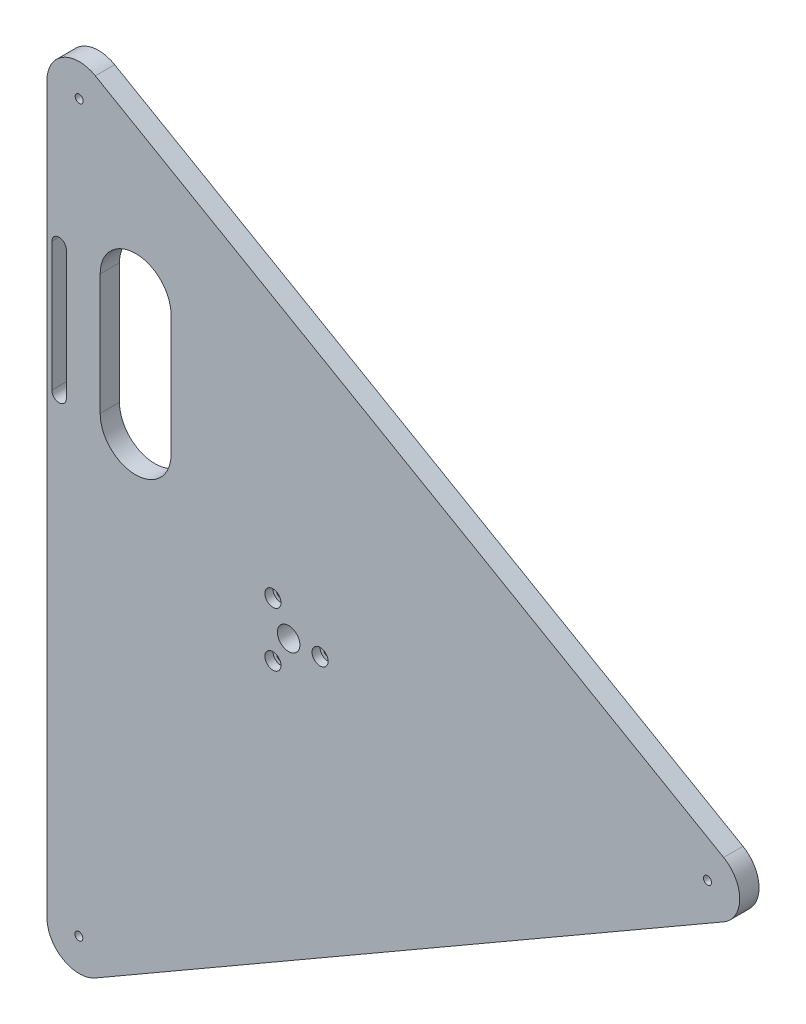
from build123d import *

# Parameters (mm, degrees)
BOSS_EXTRU_1_DEPTH                                 = 12
TROU_TARAUD_M61_D                                  = 5
TROU_TARAUD_M62_D                                  = 5
CHAMBRAGE_POUR_VIS_T_TE_HEXAGONALE_M51_D           = 5.5
CHAMBRAGE_POUR_VIS_T_TE_HEXAGONALE_M51_CBORE_D     = 10
CHAMBRAGE_POUR_VIS_T_TE_HEXAGONALE_M51_CBORE_DEPTH = 5
ESQUISSE11_R                                       = 7
ENL_V_MAT_EXTRU_1_DEPTH                            = 13
R_P_TITION_CIRCULAIRE1_COUNT                       = 3
ESQUISSE12_R                                       = 23.25
ENL_V_MAT_EXTRU_2_DEPTH                            = 1
ENL_V_MAT_EXTRU_4_DEPTH                            = 13
ENL_V_MAT_EXTRU_5_DEPTH                            = 13
ENL_V_MAT_EXTRU_6_DEPTH                            = 9


with BuildPart() as part:
    # Esquisse1 → Boss.-Extru.1 (new body)
    with BuildSketch(Plane.XY):
        with BuildLine():
            Line((270, 17.320508076), (-120, 242.48711306))
            ThreePointArc((-120, 242.48711306), (-140, 242.48711306), (-150, 225.166604984))
            Line((-150, 225.166604984), (-150, -225.166604984))
            ThreePointArc((-150, -225.166604984), (-140, -242.48711306), (-120, -242.48711306))
            Line((-120, -242.48711306), (270, -17.320508076))
            ThreePointArc((270, -17.320508076), (280, 0), (270, 17.320508076))
        make_face()
    extrude(amount=BOSS_EXTRU_1_DEPTH)

    # Trou taraudé M61 (through all)
    with Locations(Plane(origin=(0, 0, 0), x_dir=(1, 0, 0), z_dir=(0, 0, -1))):
        with Locations((260, 0)):
            Hole(TROU_TARAUD_M61_D / 2)

    # Trou taraudé M62 (through all)
    with Locations(Plane.XY.offset(12)):
        with Locations((-130.266309147, -225.083745367), (-130, 225.166604984)):
            Hole(TROU_TARAUD_M62_D / 2)

    # Chambrage pour vis à tête hexagonale M51 (through all)
    with Locations(Plane.XY.offset(12)):
        with Locations((19.5, 0)):
            chambrage_pour_vis_t_te_hexagonale_m51 = CounterBoreHole(CHAMBRAGE_POUR_VIS_T_TE_HEXAGONALE_M51_D / 2, CHAMBRAGE_POUR_VIS_T_TE_HEXAGONALE_M51_CBORE_D / 2, CHAMBRAGE_POUR_VIS_T_TE_HEXAGONALE_M51_CBORE_DEPTH)

    # Esquisse11 → Enlèv. mat.-Extru.1 (cut, through all)
    with BuildSketch(Plane.XY.offset(12)):
        Circle(ESQUISSE11_R)
    extrude(amount=-ENL_V_MAT_EXTRU_1_DEPTH, mode=Mode.SUBTRACT)

    # Répétition circulaire1: Chambrage pour vis à tête hexagonale M51 ×3 about axis
    r_p_tition_circulaire1_axis = Axis((0, 0, 0), (0, 0, 1))
    for i in range(1, R_P_TITION_CIRCULAIRE1_COUNT):
        add(chambrage_pour_vis_t_te_hexagonale_m51.rotate(r_p_tition_circulaire1_axis, i * 360 / R_P_TITION_CIRCULAIRE1_COUNT), mode=Mode.SUBTRACT)

    # Esquisse12 → Enlèv. mat.-Extru.2 (cut)
    with BuildSketch(Plane(origin=(0, 0, 0), x_dir=(-1, 0, 0), z_dir=(0, 0, -1))):
        Circle(ESQUISSE12_R)
    extrude(amount=-ENL_V_MAT_EXTRU_2_DEPTH, mode=Mode.SUBTRACT)

    # Esquisse15 → Enlèv. mat.-Extru.4 (cut, through all)
    with BuildSketch(Plane(origin=(0, 0, 0), x_dir=(-1, 0, 0), z_dir=(0, 0, -1))):
        with BuildLine():
            Line((117, 137.502524439), (117, 62.497475561))
            ThreePointArc((117, 62.497475561), (95, 40.497475561), (73, 62.497475561))
            Line((73, 62.497475561), (73, 137.502524439))
            ThreePointArc((73, 137.502524439), (95, 159.502524439), (117, 137.502524439))
        make_face()
    extrude(amount=-ENL_V_MAT_EXTRU_4_DEPTH, mode=Mode.SUBTRACT)

    # Esquisse16 → Enlèv. mat.-Extru.5 (cut, through all)
    with BuildSketch(Plane.XY.offset(12)):
        with BuildLine():
            Line((-139.9, 140), (-139.9, 60))
            ThreePointArc((-139.9, 60), (-142.5, 57.4), (-145.1, 60))
            Line((-145.1, 60), (-145.1, 140))
            ThreePointArc((-145.1, 140), (-142.5, 142.6), (-139.9, 140))
        make_face()
    extrude(amount=-ENL_V_MAT_EXTRU_5_DEPTH, mode=Mode.SUBTRACT)

    # Esquisse17 → Enlèv. mat.-Extru.6 (cut)
    with BuildSketch(Plane.XY.offset(12)):
        with BuildLine():
            Line((-138, 140), (-138, 60))
            ThreePointArc((-138, 60), (-142.5, 55.5), (-147, 60))
            Line((-147, 60), (-147, 140))
            ThreePointArc((-147, 140), (-142.5, 144.5), (-138, 140))
        make_face()
    extrude(amount=-ENL_V_MAT_EXTRU_6_DEPTH, mode=Mode.SUBTRACT)


solid = part.part
